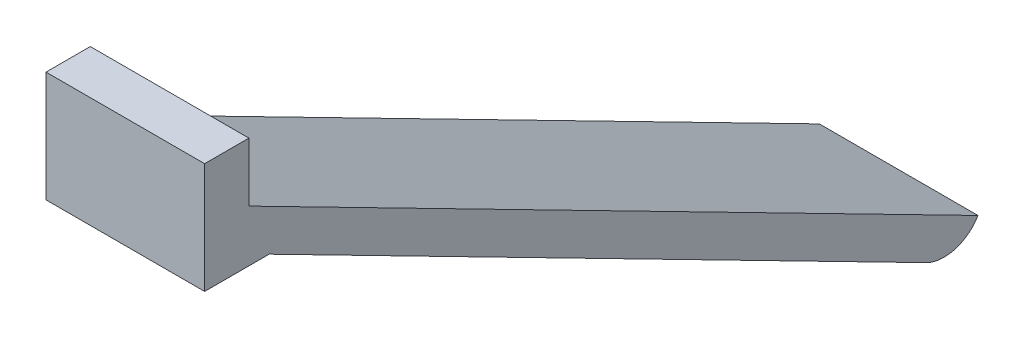
from build123d import *

# Parameters (mm, degrees)
BOSS_EXTRUDE1_DEPTH = 4.3


with BuildPart() as part:
    # Sketch1 → Boss-Extrude1 (new body)
    with BuildSketch(Plane(origin=(0, 0, 0), x_dir=(0, 0, -1), z_dir=(1, 0, 0))):
        with BuildLine():
            ThreePointArc((-11.083862383, -16.615210797), (-10.301073063, -16.690701101), (-9.678172689, -16.210645864))
            Line((-9.678172689, -16.210645864), (-29.442415971, -6.108537965))
            Line((-29.442415971, -6.108537965), (-29.442415971, -4.512715584))
            Line((-29.442415971, -4.512715584), (-30.642415971, -4.512715584))
            Line((-30.642415971, -4.512715584), (-30.642415971, -7.512715584))
            Line((-30.642415971, -7.512715584), (-28.892415971, -7.512715584))
            Line((-28.892415971, -7.512715584), (-11.083862383, -16.615210797))
        make_face()
    extrude(amount=BOSS_EXTRUDE1_DEPTH)


solid = part.part
